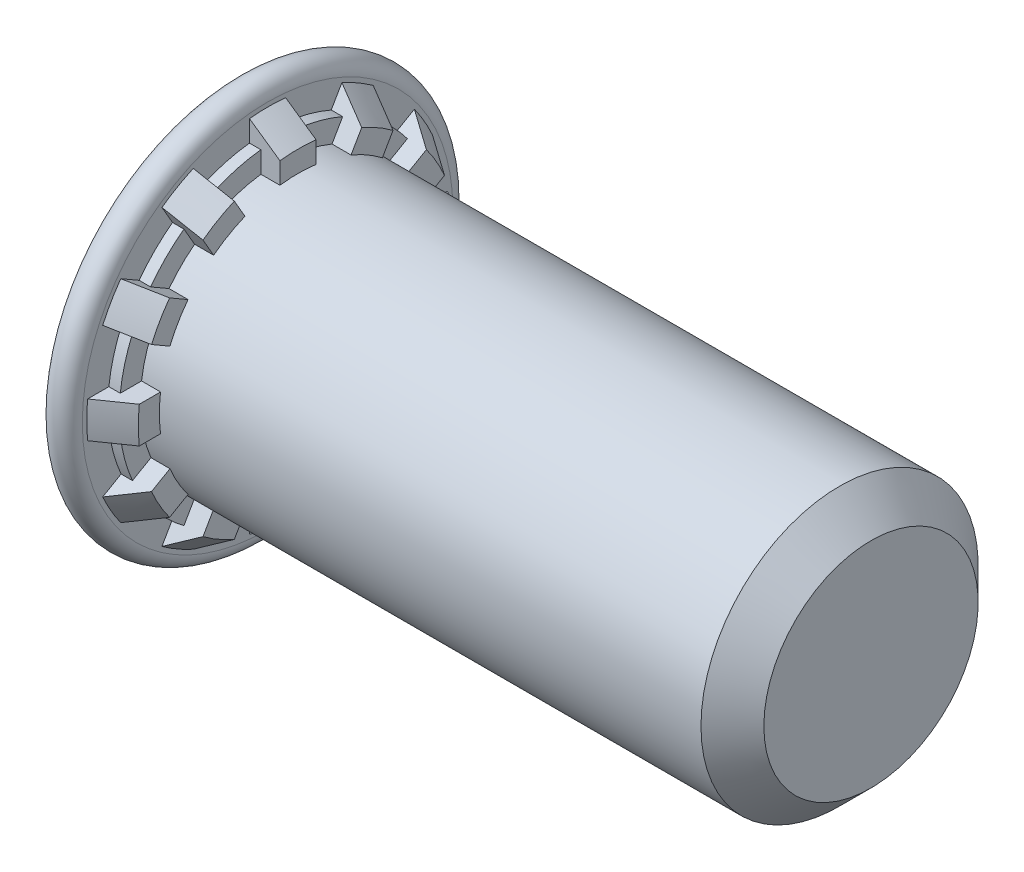
from build123d import *

# Parameters (mm, degrees)
RIBCUT1_DEPTH    = 0.28575
RIBCUT2_DEPTH    = 0.4572
RIBCUTSPAT_COUNT = 12
RIBCUTSPAT_ANGLE = 330


with BuildPart() as part:
    # BodySke → BaseBody (revolve)
    with BuildSketch(Plane.XY):
        with BuildLine():
            Line((0, 0), (0, 2.77876))
            Line((0, 2.77876), (0.00508, 2.77876))
            Line((0.00508, 2.77876), (0.00508, 2.78384))
            ThreePointArc((0.00508, 2.78384), (0.23114, 3.0099), (0.4572, 2.78384))
            Line((0.4572, 2.78384), (0.4572, 2.7178))
            Line((0.4572, 2.7178), (0.9144, 2.4003))
            Line((0.9144, 2.4003), (0.9144, 2.0828))
            Line((0.9144, 2.0828), (9.05256, 2.0828))
            Line((9.05256, 2.0828), (9.525, 1.61036))
            Line((9.525, 1.61036), (9.525, 0))
            Line((9.525, 0), (0, 0))
        make_face()
    revolve(axis=Axis((0, 0, 0), (1, 0, 0)))

    # RibCut1Ske → RibCut1 (cut)
    with BuildSketch(Plane(origin=(0.9144, 0, 0), x_dir=(0, 0, -1), z_dir=(1, 0, 0))):
        with BuildLine():
            Line((0.271859953, 2.064981357), (0.271859953, 2.997597401))
            ThreePointArc((0.271859953, 2.997597401), (0.779019444, 2.907340145), (1.263361075, 2.731925476))
            Line((1.263361075, 2.731925476), (0.797053053, 1.92425629))
            ThreePointArc((0.797053053, 1.92425629), (0.539068307, 2.011830311), (0.271859953, 2.064981357))
        make_face()
    ribcut1 = extrude(amount=-RIBCUT1_DEPTH, mode=Mode.SUBTRACT)

    # RibCut2Ske → RibCut2 (cut)
    with BuildSketch(Plane(origin=(0.9144, 0, 0), x_dir=(0, 0, -1), z_dir=(1, 0, 0))):
        with BuildLine():
            Line((0.271859953, 2.384854766), (0.271859953, 2.997597401))
            ThreePointArc((0.271859953, 2.997597401), (0.779019444, 2.907340145), (1.263361075, 2.731925476))
            Line((1.263361075, 2.731925476), (0.956989757, 2.201274788))
            ThreePointArc((0.956989757, 2.201274788), (0.621243354, 2.318511761), (0.271859953, 2.384854766))
        make_face()
    ribcut2 = extrude(amount=-RIBCUT2_DEPTH, mode=Mode.SUBTRACT)

    # RibCutsPat: RibCut1, RibCut2 ×12 about axis
    ribcutspat_axis = Axis((0, 0, 0), (1, 0, 0))
    for i in range(1, RIBCUTSPAT_COUNT):
        add(ribcut1.rotate(ribcutspat_axis, i * RIBCUTSPAT_ANGLE / (RIBCUTSPAT_COUNT - 1)), mode=Mode.SUBTRACT)
        add(ribcut2.rotate(ribcutspat_axis, i * RIBCUTSPAT_ANGLE / (RIBCUTSPAT_COUNT - 1)), mode=Mode.SUBTRACT)


solid = part.part
